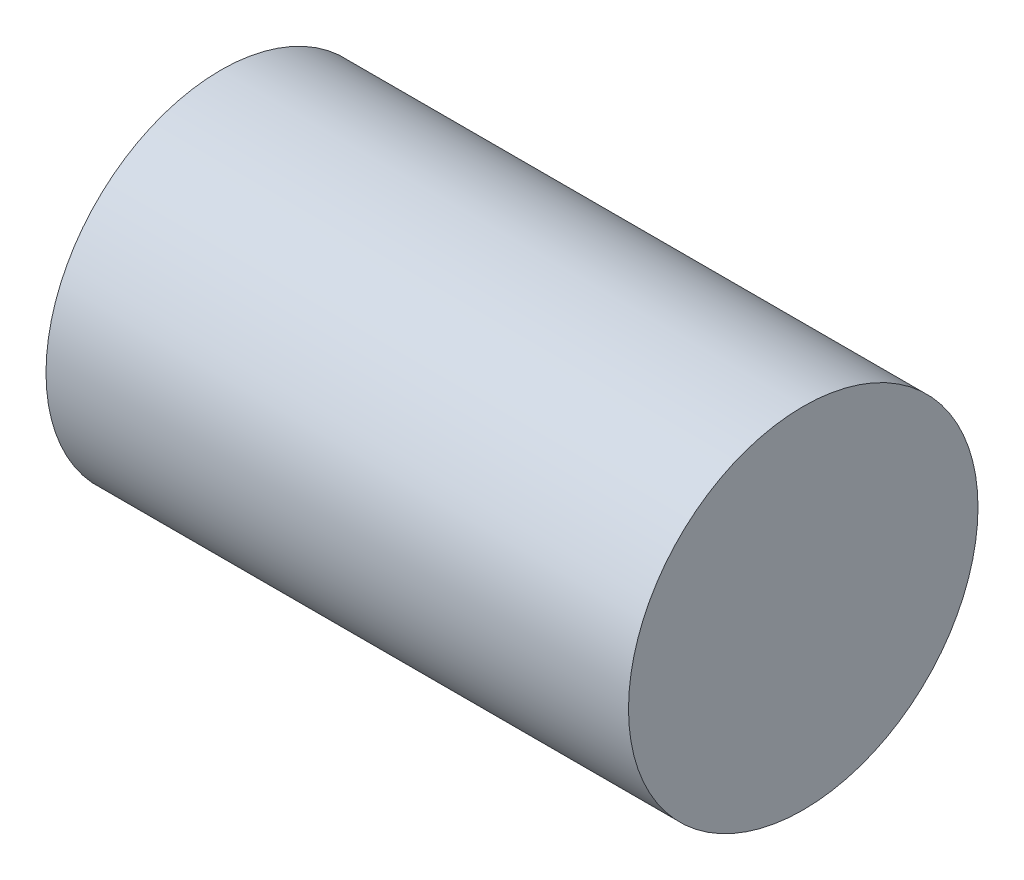
from build123d import *

# Parameters (mm, degrees)
SKETCH1_R           = 1.5
BOSS_EXTRUDE1_DEPTH = 5


with BuildPart() as part:
    # Sketch1 → Boss-Extrude1 (new body)
    with BuildSketch(Plane(origin=(0, 0, 0), x_dir=(0, 0, -1), z_dir=(1, 0, 0))):
        Circle(SKETCH1_R)
    extrude(amount=BOSS_EXTRUDE1_DEPTH)


solid = part.part
